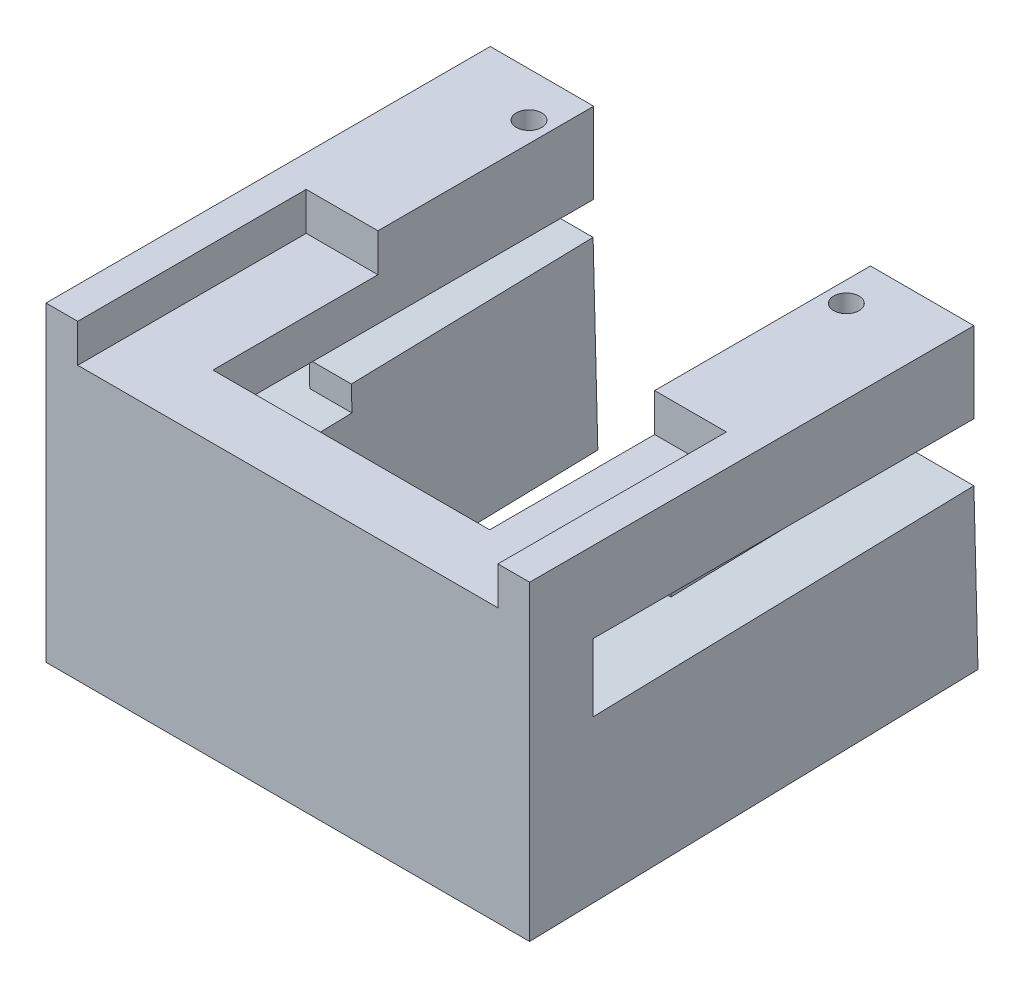
from build123d import *

# Parameters (mm, degrees)
BOSS_EXTRUDE1_DEPTH      = 19.05
SKETCH2_R                = 1
SKETCH2_W                = 21.8000072
SKETCH2_H                = 32.97884159
CUT_EXTRUDE1_DEPTH       = 25.515096105
SKETCH3_W                = 33.10001
SKETCH3_H                = 18
CUT_EXTRUDE2_DEPTH       = 3
SKETCH4_W                = 3.3239964
SKETCH4_H                = 19.05
BOSS_EXTRUDE2_DEPTH      = 2
BOSS_EXTRUDE2_DEPTH_BACK = 12.7


with BuildPart() as part:
    # Sketch1 → Boss-Extrude1 (new body, symmetric)
    with BuildSketch(Plane(origin=(0, 0, 0), x_dir=(0, 0, -1), z_dir=(1, 0, 0))):
        Polygon((35, 1.055980791), (35, 7.405980791), (0, 7.405980791), (0, -7.405980791), (35.076175279, -6.515045939), (35, -3.516019209), (5, -4.278019209), (5, 1.055980791), align=None)
        Polygon((0, -17.109115314), (35.322475992, -16.211924424), (35.076175279, -6.515045939), (0, -7.405980791), align=None)
    extrude(amount=BOSS_EXTRUDE1_DEPTH, both=True)

    # Sketch2 → Cut-Extrude1 (cut, through all)
    with BuildSketch(Plane(origin=(0, 7.405980791, 0), x_dir=(1, 0, 0), z_dir=(0, 1, 0))):
        with Locations((-12.5, 31.5)):
            Circle(SKETCH2_R)
        with Locations((12.5, 31.5)):
            Circle(SKETCH2_R)
        with Locations((0, 21.489420795)):
            Rectangle(SKETCH2_W, SKETCH2_H)
    extrude(amount=-CUT_EXTRUDE1_DEPTH, mode=Mode.SUBTRACT)

    # Sketch3 → Cut-Extrude2 (cut)
    with BuildSketch(Plane(origin=(0, 7.405980791, 0), x_dir=(1, 0, 0), z_dir=(0, 1, 0))):
        with Locations((0, 9)):
            Rectangle(SKETCH3_W, SKETCH3_H)
    extrude(amount=-CUT_EXTRUDE2_DEPTH, mode=Mode.SUBTRACT)

    # Sketch4 → Boss-Extrude2 (add, two sides)
    with BuildSketch(Plane(origin=(0, -4.402179099, -0.111815349), x_dir=(1, 0, 0), z_dir=(0, 0.999677576, 0.02539181))) as boss_extrude2_sk:
        with Locations((12.5620018, 25.374437067)):
            Rectangle(SKETCH4_W, SKETCH4_H)
        with Locations((-12.5620018, 25.374437067)):
            Rectangle(SKETCH4_W, SKETCH4_H)
    extrude(amount=BOSS_EXTRUDE2_DEPTH)
    extrude(boss_extrude2_sk.sketch, amount=-BOSS_EXTRUDE2_DEPTH_BACK)


solid = part.part
